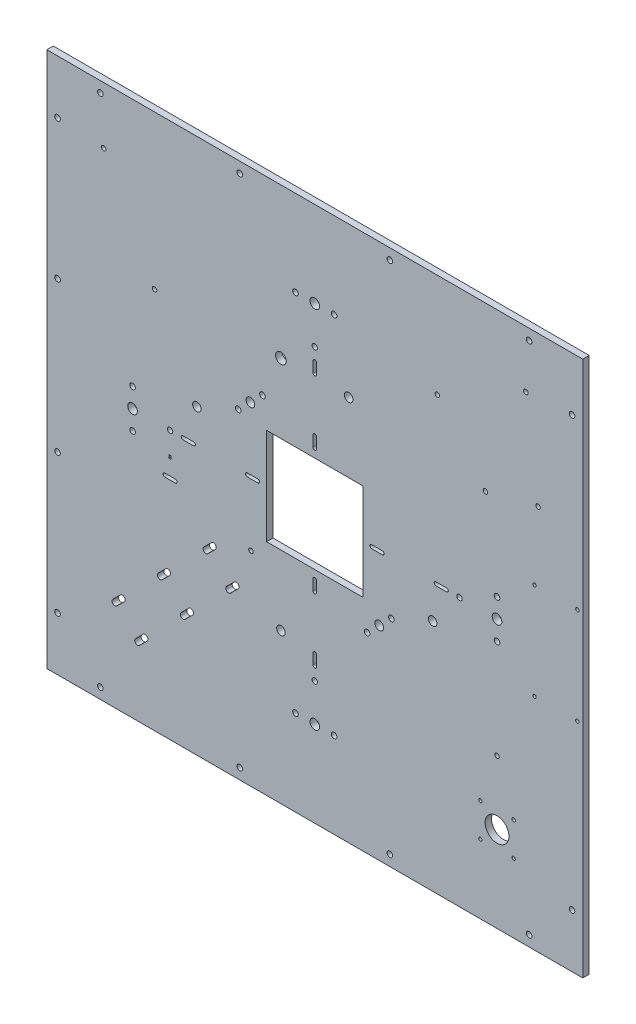
from build123d import *

# Parameters (mm, degrees)
SKETCH_1_W             = 500
SKETCH_1_H             = 500
EXTRUDE_1_DEPTH        = 6
SKETCH_2_W             = 90
SKETCH_2_H             = 90
CUT_EXTRUDE_565_DEPTH  = 7
CUT_EXTRUDE_1336_DEPTH = 7
SKETCH_4_R             = 4.5
SKETCH_4_R_2           = 2.6
CUT_EXTRUDE_2097_DEPTH = 7
CUT_EXTRUDE_3578_DEPTH = 7
SKETCH_7_R             = 4.05
SKETCH_7_R_2           = 2.6
CUT_EXTRUDE_4274_DEPTH = 7
SKETCH_8_R             = 2.6
CUT_EXTRUDE_4782_DEPTH = 7
SKETCH_5_R             = 11.1
SKETCH_5_R_2           = 1.6
SKETCH_5_R_3           = 1.55
CUT_EXTRUDE_4824_DEPTH = 7
SKETCH_9_R             = 2.5
CUT_EXTRUDE_4987_DEPTH = 7
SKETCH_10_R            = 1.6
MARK_DEPTH             = 7
SKETCH_11_W            = 2
SKETCH_11_H            = 3
CUT_EXTRUDE_5444_DEPTH = 7
SKETCH_12_R            = 4
CUT_EXTRUDE_5629_DEPTH = 7
SKETCH_13_R            = 2.1
CUT_EXTRUDE_3_DEPTH    = 7
SKETCH_14_R            = 5
CUT_EXTRUDE_4_DEPTH    = 7


with BuildPart() as part:
    # 草图1 → 凸台-拉伸1 (new body)
    with BuildSketch(Plane.XY):
        with Locations((250, -250)):
            Rectangle(SKETCH_1_W, SKETCH_1_H)
    extrude(amount=EXTRUDE_1_DEPTH)

    # 草图2 → Cut-Extrude 565 (cut, through all)
    with BuildSketch(Plane.XY.offset(6)):
        with Locations((250, -250)):
            Rectangle(SKETCH_2_W, SKETCH_2_H)
    extrude(amount=-CUT_EXTRUDE_565_DEPTH, mode=Mode.SUBTRACT)

    # 草图3 → Cut-Extrude 1336 (cut, through all)
    with BuildSketch(Plane.XY.offset(6)):
        with BuildLine():
            Line((248.4, -137), (248.4, -127))
            ThreePointArc((248.4, -127), (250, -125.4), (251.6, -127))
            Line((251.6, -127), (251.6, -137))
            ThreePointArc((251.6, -137), (250, -138.6), (248.4, -137))
        make_face()
        with BuildLine():
            Line((248.4, -197), (248.4, -187))
            ThreePointArc((248.4, -187), (250, -185.4), (251.6, -187))
            Line((251.6, -187), (251.6, -197))
            ThreePointArc((251.6, -197), (250, -198.6), (248.4, -197))
        make_face()
        with BuildLine():
            Line((248.4, -303), (248.4, -313))
            ThreePointArc((248.4, -313), (250, -314.6), (251.6, -313))
            Line((251.6, -313), (251.6, -303))
            ThreePointArc((251.6, -303), (250, -301.4), (248.4, -303))
        make_face()
        with BuildLine():
            Line((248.4, -363), (248.4, -373))
            ThreePointArc((248.4, -373), (250, -374.6), (251.6, -373))
            Line((251.6, -373), (251.6, -363))
            ThreePointArc((251.6, -363), (250, -361.4), (248.4, -363))
        make_face()
        with BuildLine():
            Line((187, -248.4), (197, -248.4))
            ThreePointArc((197, -248.4), (198.6, -250), (197, -251.6))
            Line((197, -251.6), (187, -251.6))
            ThreePointArc((187, -251.6), (185.4, -250), (187, -248.4))
        make_face()
        with BuildLine():
            Line((137, -251.6), (127, -251.6))
            ThreePointArc((127, -251.6), (125.4, -250), (127, -248.4))
            Line((127, -248.4), (137, -248.4))
            ThreePointArc((137, -248.4), (138.6, -250), (137, -251.6))
        make_face()
        with BuildLine():
            Line((313, -248.4), (303, -248.4))
            ThreePointArc((303, -248.4), (301.4, -250), (303, -251.6))
            Line((303, -251.6), (313, -251.6))
            ThreePointArc((313, -251.6), (314.6, -250), (313, -248.4))
        make_face()
        with BuildLine():
            Line((363, -251.6), (373, -251.6))
            ThreePointArc((373, -251.6), (374.6, -250), (373, -248.4))
            Line((373, -248.4), (363, -248.4))
            ThreePointArc((363, -248.4), (361.4, -250), (363, -251.6))
        make_face()
    extrude(amount=-CUT_EXTRUDE_1336_DEPTH, mode=Mode.SUBTRACT)

    # 草图4 → Cut-Extrude 2097 (cut, through all)
    with BuildSketch(Plane.XY.offset(6)):
        with Locations((420, -250)):
            Circle(SKETCH_4_R)
        with Locations((420, -268)):
            Circle(SKETCH_4_R_2)
        with Locations((420, -232)):
            Circle(SKETCH_4_R_2)
        with Locations((250, -420)):
            Circle(SKETCH_4_R)
        with Locations((232, -420)):
            Circle(SKETCH_4_R_2)
        with Locations((268, -420)):
            Circle(SKETCH_4_R_2)
        with Locations((80, -250)):
            Circle(SKETCH_4_R)
        with Locations((80, -232)):
            Circle(SKETCH_4_R_2)
        with Locations((80, -268)):
            Circle(SKETCH_4_R_2)
        with Locations((250, -80)):
            Circle(SKETCH_4_R)
        with Locations((268, -80)):
            Circle(SKETCH_4_R_2)
        with Locations((232, -80)):
            Circle(SKETCH_4_R_2)
    extrude(amount=-CUT_EXTRUDE_2097_DEPTH, mode=Mode.SUBTRACT)

    # 草图6 → Cut-Extrude 3578 (cut, through all)
    with BuildSketch(Plane(origin=(0, 0, 0), x_dir=(-1, 0, 0), z_dir=(0, 0, -1))):
        with BuildLine():
            Line((-174.818772789, -342.621985721), (-167.739030626, -349.684368528))
            ThreePointArc((-167.739030626, -349.684368528), (-167.734517194, -353.36132102), (-171.411469686, -353.365834453))
            Line((-171.411469686, -353.365834453), (-178.491211848, -346.303451645))
            ThreePointArc((-178.491211848, -346.303451645), (-178.495725281, -342.626499153), (-174.818772789, -342.621985721))
        make_face()
        with BuildLine():
            Line((-89.861866841, -427.370579408), (-82.782124679, -434.432962215))
            ThreePointArc((-82.782124679, -434.432962215), (-82.777611247, -438.109914707), (-86.454563739, -438.114428139))
            Line((-86.454563739, -438.114428139), (-93.534305901, -431.052045332))
            ThreePointArc((-93.534305901, -431.052045332), (-93.538819333, -427.37509284), (-89.861866841, -427.370579408))
        make_face()
        with BuildLine():
            Line((-72.347157479, -409.812818845), (-65.267415317, -416.875201653))
            ThreePointArc((-65.267415317, -416.875201653), (-61.590462825, -416.87068822), (-61.594976257, -413.193735728))
            Line((-61.594976257, -413.193735728), (-68.67471842, -406.131352921))
            ThreePointArc((-68.67471842, -406.131352921), (-72.351670912, -406.135866353), (-72.347157479, -409.812818845))
        make_face()
        with BuildLine():
            Line((-157.304063427, -325.064225159), (-150.224321264, -332.126607966))
            ThreePointArc((-150.224321264, -332.126607966), (-146.547368772, -332.122094534), (-146.551882205, -328.445142041))
            Line((-146.551882205, -328.445142041), (-153.631624367, -321.382759234))
            ThreePointArc((-153.631624367, -321.382759234), (-157.308576859, -321.387272667), (-157.304063427, -325.064225159))
        make_face()
        with BuildLine():
            Line((-132.385770641, -385.046305421), (-125.314702829, -392.117373233))
            ThreePointArc((-125.314702829, -392.117373233), (-125.314702829, -395.794328495), (-128.991658091, -395.794328495))
            Line((-128.991658091, -395.794328495), (-136.062725903, -388.723260683))
            ThreePointArc((-136.062725903, -388.723260683), (-136.062725903, -385.046305421), (-132.385770641, -385.046305421))
        make_face()
        with BuildLine():
            Line((-114.775699328, -367.392948508), (-107.687293483, -374.446635669))
            ThreePointArc((-107.687293483, -374.446635669), (-104.010349301, -374.437608811), (-104.019376159, -370.76066463))
            Line((-104.019376159, -370.76066463), (-111.107782004, -363.706977468))
            ThreePointArc((-111.107782004, -363.706977468), (-114.784726186, -363.716004326), (-114.775699328, -367.392948508))
        make_face()
    extrude(amount=-CUT_EXTRUDE_3578_DEPTH, mode=Mode.SUBTRACT)

    # 草图7 → Cut-Extrude 4274 (cut, through all)
    with BuildSketch(Plane(origin=(0, 0, 0), x_dir=(-1, 0, 0), z_dir=(0, 0, -1))):
        with Locations((-310.104076401, -310.104076401)):
            Circle(SKETCH_7_R)
        with Locations((-298.790367902, -321.4177849)):
            Circle(SKETCH_7_R_2)
        with Locations((-178.5822151, -201.209632098)):
            Circle(SKETCH_7_R_2)
        with Locations((-189.895923599, -189.895923599)):
            Circle(SKETCH_7_R)
        with Locations((-201.209632098, -178.5822151)):
            Circle(SKETCH_7_R_2)
        with Locations((-321.4177849, -298.790367902)):
            Circle(SKETCH_7_R_2)
    extrude(amount=-CUT_EXTRUDE_4274_DEPTH, mode=Mode.SUBTRACT)

    # 草图8 → Cut-Extrude 4782 (cut, through all)
    with BuildSketch(Plane(origin=(0, 0, 0), x_dir=(-1, 0, 0), z_dir=(0, 0, -1))):
        with Locations((-450, -10)):
            Circle(SKETCH_8_R)
        with Locations((-320, -10)):
            Circle(SKETCH_8_R)
        with Locations((-490, -50)):
            Circle(SKETCH_8_R)
        with Locations((-180, -10)):
            Circle(SKETCH_8_R)
        with Locations((-50, -10)):
            Circle(SKETCH_8_R)
        with Locations((-10, -180)):
            Circle(SKETCH_8_R)
        with Locations((-10, -50)):
            Circle(SKETCH_8_R)
        with Locations((-490, -450)):
            Circle(SKETCH_8_R)
        with Locations((-10, -320)):
            Circle(SKETCH_8_R)
        with Locations((-10, -450)):
            Circle(SKETCH_8_R)
        with Locations((-50, -490)):
            Circle(SKETCH_8_R)
        with Locations((-180, -490)):
            Circle(SKETCH_8_R)
        with Locations((-320, -490)):
            Circle(SKETCH_8_R)
        with Locations((-450, -490)):
            Circle(SKETCH_8_R)
    extrude(amount=-CUT_EXTRUDE_4782_DEPTH, mode=Mode.SUBTRACT)

    # 草图5 → Cut-Extrude 4824 (cut, through all)
    with BuildSketch(Plane(origin=(0, 0, 0), x_dir=(-1, 0, 0), z_dir=(0, 0, -1))):
        with Locations((-420, -420)):
            Circle(SKETCH_5_R)
        with Locations((-435.5, -404.5)):
            Circle(SKETCH_5_R_2)
        with Locations((-435.5, -435.5)):
            Circle(SKETCH_5_R_3)
        with Locations((-404.5, -435.5)):
            Circle(SKETCH_5_R_3)
        with Locations((-404.5, -404.5)):
            Circle(SKETCH_5_R_3)
    extrude(amount=-CUT_EXTRUDE_4824_DEPTH, mode=Mode.SUBTRACT)

    # 草图9 → Cut-Extrude 4987 (cut, through all)
    with BuildSketch(Plane(origin=(0, 0, 0), x_dir=(-1, 0, 0), z_dir=(0, 0, -1))):
        with Locations((-250, -115)):
            Circle(SKETCH_9_R)
        with Locations((-115, -250)):
            Circle(SKETCH_9_R)
        with Locations((-250, -385)):
            Circle(SKETCH_9_R)
        with Locations((-385, -250)):
            Circle(SKETCH_9_R)
    extrude(amount=-CUT_EXTRUDE_4987_DEPTH, mode=Mode.SUBTRACT)

    # 草图10 → mark (cut, through all)
    with BuildSketch(Plane(origin=(0, 0, 0), x_dir=(-1, 0, 0), z_dir=(0, 0, -1))):
        with Locations((-495, -295)):
            Circle(SKETCH_10_R)
        with Locations((-455, -295)):
            Circle(SKETCH_10_R)
        with Locations((-455, -205)):
            Circle(SKETCH_10_R)
        with Locations((-495, -205)):
            Circle(SKETCH_10_R)
    extrude(amount=-MARK_DEPTH, mode=Mode.SUBTRACT)

    # 草图11 → Cut-Extrude 5444 (cut, through all)
    with BuildSketch(Plane(origin=(0, 0, 0), x_dir=(-1, 0, 0), z_dir=(0, 0, -1))):
        with BuildLine():
            Line((-120, -287), (-110, -287))
            ThreePointArc((-110, -287), (-108.4, -288.6), (-110, -290.2))
            Line((-110, -290.2), (-120, -290.2))
            ThreePointArc((-120, -290.2), (-121.6, -288.6), (-120, -287))
        make_face()
        with Locations((-115, -271.6)):
            Rectangle(SKETCH_11_W, SKETCH_11_H)
    extrude(amount=-CUT_EXTRUDE_5444_DEPTH, mode=Mode.SUBTRACT)

    # 草图12 → Cut-Extrude 5629 (cut, through all)
    with BuildSketch(Plane(origin=(0, 0, 0), x_dir=(-1, 0, 0), z_dir=(0, 0, -1))):
        with Locations((-281.6, -140)):
            Circle(SKETCH_12_R)
        with Locations((-360, -281.6)):
            Circle(SKETCH_12_R)
        with Locations((-218.4, -360)):
            Circle(SKETCH_12_R)
        with Locations((-140, -218.4)):
            Circle(SKETCH_12_R)
    extrude(amount=-CUT_EXTRUDE_5629_DEPTH, mode=Mode.SUBTRACT)

    # 草图13 → 切除-拉伸3 (cut, through all)
    with BuildSketch(Plane(origin=(0, 0, 0), x_dir=(-1, 0, 0), z_dir=(0, 0, -1))):
        with Locations((-420, -360.485391833)):
            Circle(SKETCH_13_R)
        with Locations((-446.966991411, -53.033008589)):
            Circle(SKETCH_13_R)
        with Locations((-53.033008589, -53.033008589)):
            Circle(SKETCH_13_R)
        with Locations((-190.461090909, -309.538909091)):
            Circle(SKETCH_13_R)
        with Locations((-100.513688505, -143.317115932)):
            Circle(SKETCH_13_R)
        with Locations((-458.248464918, -140)):
            Circle(SKETCH_13_R)
        with Locations((-364.283495706, -96.516504294)):
            Circle(SKETCH_13_R)
        with Locations((-409.215443709, -152.251775839)):
            Circle(SKETCH_13_R)
    extrude(amount=-CUT_EXTRUDE_3_DEPTH, mode=Mode.SUBTRACT)

    # 草图14 → 切除-拉伸4 (cut, through all)
    with BuildSketch(Plane(origin=(0, 0, 0), x_dir=(-1, 0, 0), z_dir=(0, 0, -1))):
        with Locations((-218.4, -140)):
            Circle(SKETCH_14_R)
    extrude(amount=-CUT_EXTRUDE_4_DEPTH, mode=Mode.SUBTRACT)


solid = part.part
